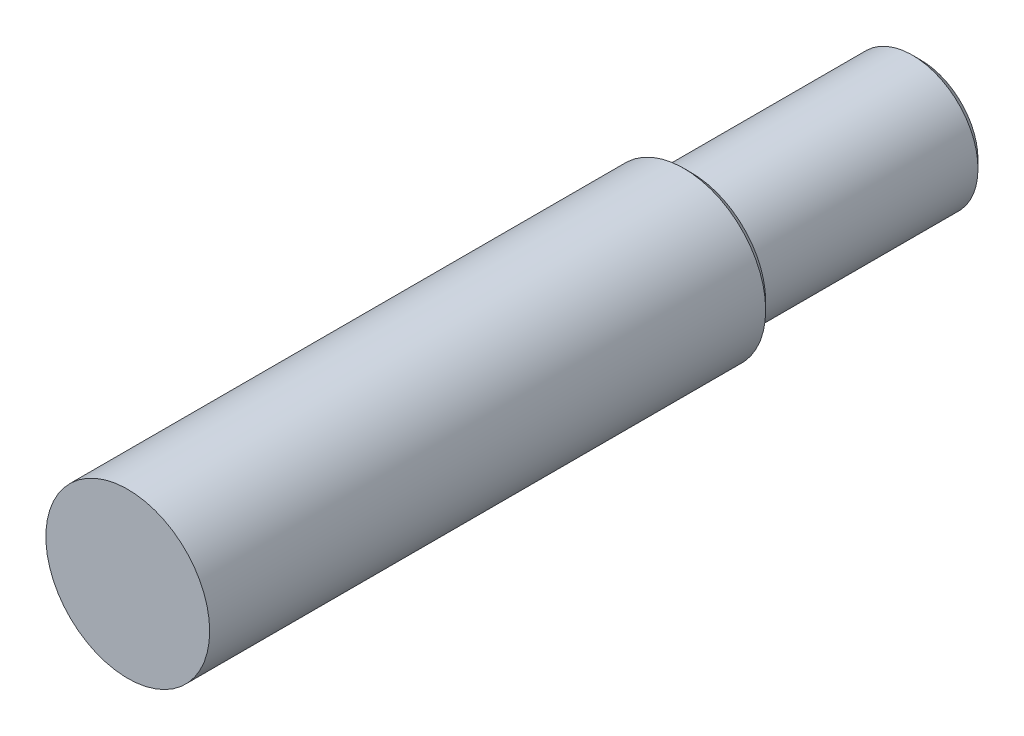
from build123d import *


with BuildPart() as part:
    # Sketch1 → Revolve1 (revolve)
    with BuildSketch(Plane(origin=(0, 0, 0), x_dir=(0, 0, -1), z_dir=(1, 0, 0))):
        Polygon((0, 0), (0, 5), (33.94, 5), (34.4, 4.54), (34.4, 4), (47.9, 4), (48.4, 3.5), (48.4, 0), align=None)
    revolve(axis=Axis((0, 0, -48.4), (0, 0, 1)))


solid = part.part
